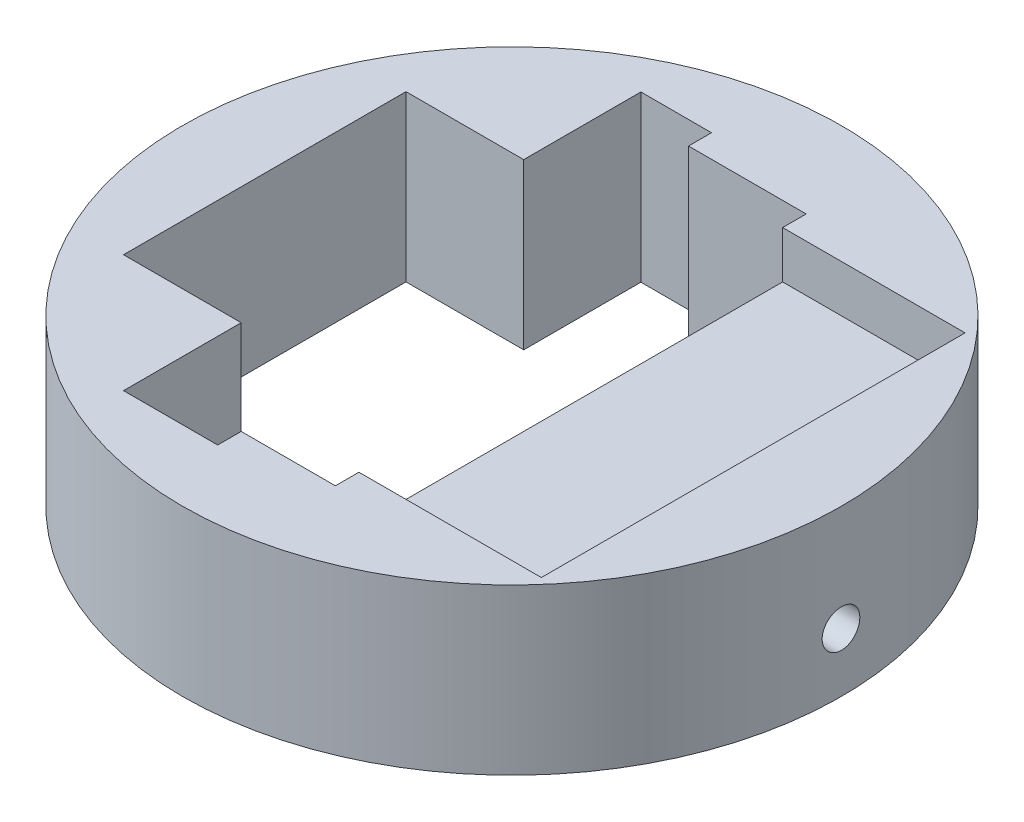
from build123d import *

# Parameters (mm, degrees)
SKETCH_3_R          = 14
EXTRUDE_2_DEPTH     = 7
CUT_EXTRUDE_1_DEPTH = 8
SKETCH_10_W         = 12
SKETCH_10_H         = 18
CUT_EXTRUDE_2_DEPTH = 2
SKETCH_12_R         = 0.8
CUT_EXTRUDE_3_DEPTH = 11.5


with BuildPart() as part:
    # Эскиз3 → Бобышка-Вытянуть2 (new body)
    with BuildSketch(Plane(origin=(0, 0, 0), x_dir=(1, 0, 0), z_dir=(0, 1, 0))):
        Circle(SKETCH_3_R)
    extrude(amount=EXTRUDE_2_DEPTH)

    # Эскиз8 → Вырез-Вытянуть1 (cut, through all)
    with BuildSketch(Plane(origin=(0, 7, 0), x_dir=(1, 0, 0), z_dir=(0, 1, 0))):
        Polygon((-2.5, 10.977260976), (-2.5, 10), (2.5, 10), (2.5, -10), (-1.5, -10), (-1.5, -11), (-5.5, -11), (-5.5, -6), (-10.5, -6), (-10.5, 6), (-5.5, 6), (-5.5, 10.977260976), align=None)
    extrude(amount=-CUT_EXTRUDE_1_DEPTH, mode=Mode.SUBTRACT)

    # Эскиз10 → Вырез-Вытянуть2 (cut)
    with BuildSketch(Plane(origin=(0, 7, 0), x_dir=(1, 0, 0), z_dir=(0, 1, 0))):
        with Locations((4.25, 0)):
            Rectangle(SKETCH_10_W, SKETCH_10_H)
    extrude(amount=-CUT_EXTRUDE_2_DEPTH, mode=Mode.SUBTRACT)

    # Эскиз12 → Вырез-Вытянуть3 (cut)
    with BuildSketch(Plane(origin=(14, 0, 0), x_dir=(0, 0, -1), z_dir=(1, 0, 0))):
        with Locations((0, 2.5)):
            Circle(SKETCH_12_R)
    extrude(amount=-CUT_EXTRUDE_3_DEPTH, mode=Mode.SUBTRACT)


solid = part.part
